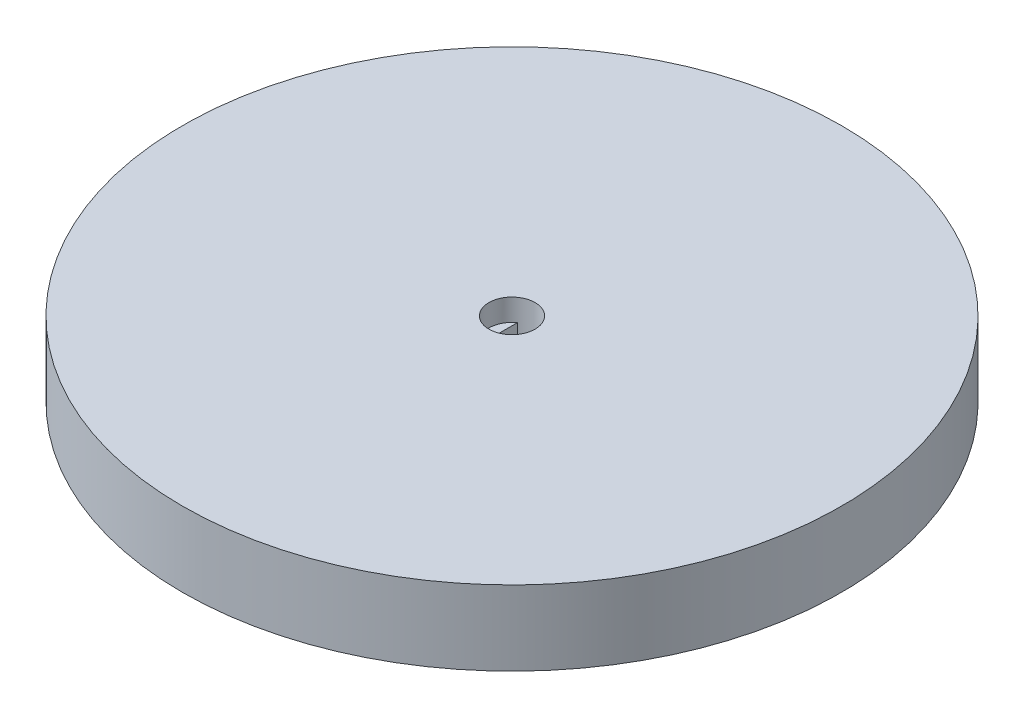
from build123d import *

# Parameters (mm, degrees)
SKETCH1_R           = 37.5
BOSS_EXTRUDE1_DEPTH = 8.5
SKETCH2_R           = 2.625
CUT_EXTRUDE1_DEPTH  = 2.5
CUT_EXTRUDE2_DEPTH  = 6


with BuildPart() as part:
    # Sketch1 → Boss-Extrude1 (new body)
    with BuildSketch(Plane(origin=(0, 0, 0), x_dir=(1, 0, 0), z_dir=(0, 1, 0))):
        Circle(SKETCH1_R)
    extrude(amount=BOSS_EXTRUDE1_DEPTH)

    # Sketch2 → Cut-Extrude1 (cut)
    with BuildSketch(Plane(origin=(0, 8.5, 0), x_dir=(1, 0, 0), z_dir=(0, 1, 0))):
        Circle(SKETCH2_R)
    extrude(amount=-CUT_EXTRUDE1_DEPTH, mode=Mode.SUBTRACT)

    # Sketch3 → Cut-Extrude2 (cut)
    with BuildSketch(Plane(origin=(0, 6, 0), x_dir=(1, 0, 0), z_dir=(0, 1, 0))):
        with BuildLine():
            Line((-1.525, 2.136586062), (-1.525, -2.136586062))
            ThreePointArc((-1.525, -2.136586062), (0, -2.625), (1.525, -2.136586062))
            Line((1.525, -2.136586062), (1.525, 2.136586062))
            ThreePointArc((1.525, 2.136586062), (0, 2.625), (-1.525, 2.136586062))
        make_face()
    extrude(amount=-CUT_EXTRUDE2_DEPTH, mode=Mode.SUBTRACT)


solid = part.part
